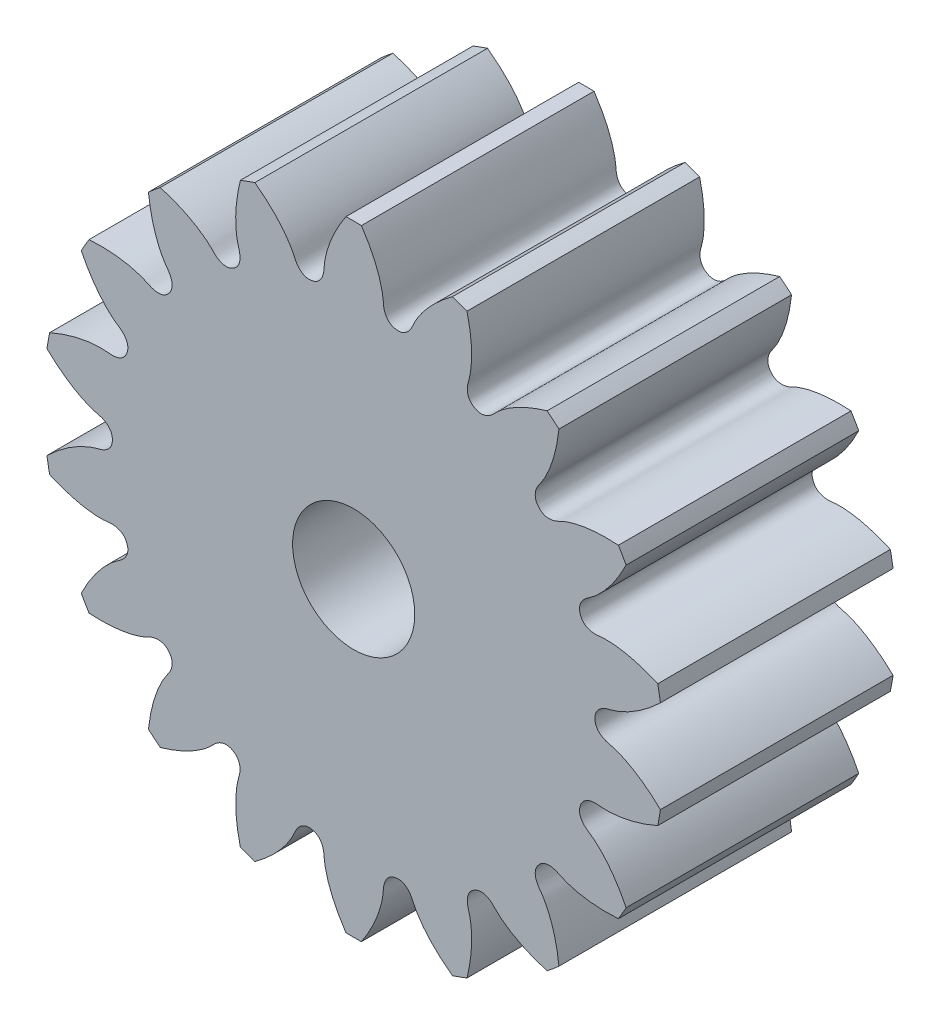
from build123d import *

# Parameters (mm, degrees)
SKETCHREVOLVESPURPINION_W       = 19.05
SKETCHREVOLVESPURPINION_H       = 25.399999619
TOOTHEXTRUDECUTSPURPINION_DEPTH = 9.525
PATTERNSPURPINION_COUNT         = 18
SCALE1_SCALE                    = 0.5
SKETCH1_R                       = 2.5
CUT_EXTRUDE1_DEPTH              = 7
SKETCH2_R                       = 4.457914934
CUT_EXTRUDE2_DEPTH              = 2


with BuildPart() as part:
    # SketchRevolveSpurPinion → SpurPinion (revolve)
    with BuildSketch(Plane(origin=(0, 0, 0), x_dir=(0, 0, -1), z_dir=(1, 0, 0))):
        with Locations((0, 12.69999981)):
            Rectangle(SKETCHREVOLVESPURPINION_W, SKETCHREVOLVESPURPINION_H)
    revolve(axis=Axis((0, 0, 0), (0, 0, -1)))

    # SketchToothSpurPinion → ToothExtrudeCutSpurPinion (cut, symmetric)
    with BuildSketch(Plane.XY):
        with BuildLine():
            ThreePointArc((25.228049741, 3.895281208), (25.526999617, 0), (25.228049741, -3.895281208))
            add(Edge.make_bspline(
                [(25.228049741, -3.895281208), (24.985708325, -3.656963855), (24.619867749, -3.320884229), (24.122107985, -2.91205718), (23.77001484, -2.643474463), (23.430405038, -2.403221533), (23.104832913, -2.190032591), (22.794777047, -2.002567565), (22.501637526, -1.839414516), (22.226730879, -1.699100875), (21.971293633, -1.580073029), (21.73645851, -1.480780413), (21.523319453, -1.399423733), (21.332716313, -1.334766763), (21.087797744, -1.259721665), (20.881340201, -1.218402925), (20.716532161, -1.166402443), (20.65727135, -1.145924244), (20.598989605, -1.123830197), (20.541637165, -1.100038396), (20.485168126, -1.074420874), (20.429539014, -1.046831403), (20.374713493, -1.017093579), (20.32066721, -0.984999358), (20.267394928, -0.950305053), (20.214920003, -0.912728914), (20.163306836, -0.87195025), (20.112676677, -0.827611695), (20.063226859, -0.779326422), (20.01525285, -0.726692795), (19.969171221, -0.669319265), (19.925540245, -0.606862151), (19.885070744, -0.539077773), (19.848624899, -0.465886919), (19.81717107, -0.387446583), (19.791777807, -0.304209858), (19.773295709, -0.216979414), (19.763860708, -0.133588195), (19.760541449, -0.060958866), (19.761488252, 0), (19.760541449, 0.060958866), (19.763860708, 0.133588195), (19.773295709, 0.216979414), (19.791777807, 0.304209858), (19.81717107, 0.387446583), (19.848624899, 0.465886919), (19.885070744, 0.539077773), (19.925540245, 0.606862151), (19.969171221, 0.669319265), (20.01525285, 0.726692795), (20.063226859, 0.779326422), (20.112676677, 0.827611695), (20.163306836, 0.87195025), (20.214920003, 0.912728914), (20.267394928, 0.950305053), (20.32066721, 0.984999358), (20.374713493, 1.017093579), (20.429539014, 1.046831403), (20.485168126, 1.074420874), (20.541637165, 1.100038396), (20.598989605, 1.123830197), (20.65727135, 1.145924244), (20.716532161, 1.166402443), (20.881340201, 1.218402925), (21.087797744, 1.259721665), (21.332716313, 1.334766763), (21.523319453, 1.399423733), (21.73645851, 1.480780413), (21.971293633, 1.580073029), (22.226730879, 1.699100875), (22.501637526, 1.839414516), (22.794777047, 2.002567565), (23.104832913, 2.190032591), (23.430405038, 2.403221533), (23.77001484, 2.643474463), (24.122107985, 2.91205718), (24.619867749, 3.320884229), (24.985708325, 3.656963855), (25.228049741, 3.895281208)],
                knots=[0, 0, 0, 0, 0.073200118, 0.106910699, 0.13869496, 0.168552903, 0.196484528, 0.222489833, 0.246568819, 0.268721487, 0.288947836, 0.307247866, 0.323621578, 0.33806897, 0.350590044, 0.378768299, 0.383302055, 0.387799841, 0.392270408, 0.396723539, 0.40117016, 0.405622459, 0.410093988, 0.414599758, 0.419156287, 0.423781592, 0.428495075, 0.433317256, 0.438269296, 0.443372216, 0.448645763, 0.454106839, 0.459767521, 0.46563276, 0.471698035, 0.477947397, 0.484352479, 0.490873033, 0.495999153, 0.5, 0.504000847, 0.509126967, 0.515647521, 0.522052603, 0.528301965, 0.53436724, 0.540232479, 0.545893161, 0.551354237, 0.556627784, 0.561730704, 0.566682744, 0.571504925, 0.576218408, 0.580843713, 0.585400242, 0.589906012, 0.594377541, 0.59882984, 0.603276461, 0.607729592, 0.612200159, 0.616697945, 0.621231701, 0.649409956, 0.66193103, 0.676378422, 0.692752134, 0.711052164, 0.731278513, 0.753431181, 0.777510167, 0.803515472, 0.831447097, 0.86130504, 0.893089301, 0.926799882, 1, 1, 1, 1], degree=3))
        make_face()
    toothextrudecutspurpinion = extrude(amount=TOOTHEXTRUDECUTSPURPINION_DEPTH, both=True, mode=Mode.SUBTRACT)

    # PatternSpurPinion: ToothExtrudeCutSpurPinion ×18 about axis
    patternspurpinion_axis = Axis((0, 0, 10.4775), (0, 0, -1))
    for i in range(1, PATTERNSPURPINION_COUNT):
        add(toothextrudecutspurpinion.rotate(patternspurpinion_axis, i * 360 / PATTERNSPURPINION_COUNT), mode=Mode.SUBTRACT)


with BuildPart() as part_1:
    # Scale1: scaled about (0, 0, 0)
    add(part.part.scale(SCALE1_SCALE))

    # Sketch1 → Cut-Extrude1 (cut)
    with BuildSketch(Plane.XY.offset(4.7625)):
        Circle(SKETCH1_R)
    extrude(amount=-CUT_EXTRUDE1_DEPTH, mode=Mode.SUBTRACT)

    # Sketch2 → Cut-Extrude2 (cut)
    with BuildSketch(Plane(origin=(0, 0, -4.7625), x_dir=(-1, 0, 0), z_dir=(0, 0, -1))):
        Circle(SKETCH2_R)
    extrude(amount=-CUT_EXTRUDE2_DEPTH, mode=Mode.SUBTRACT)


solid = part_1.part
